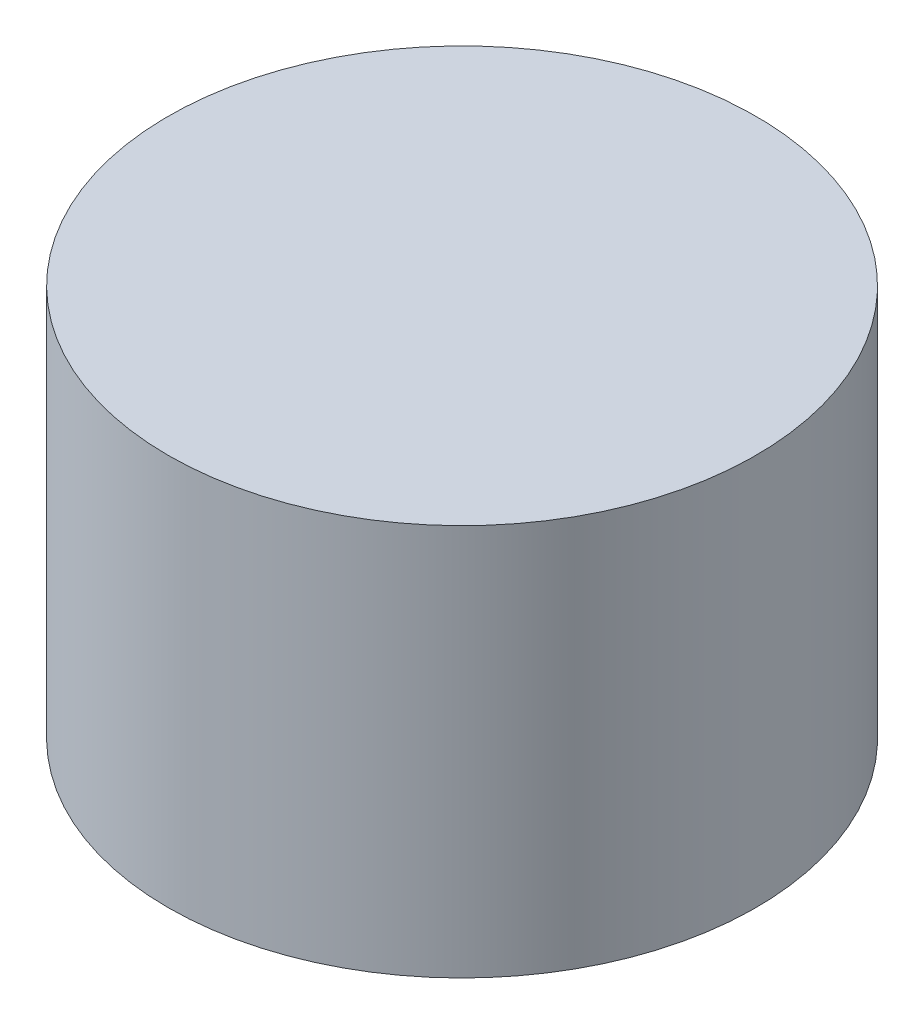
from build123d import *

# Parameters (mm, degrees)
SKETCH1_R           = 150
BOSS_EXTRUDE1_DEPTH = 200


with BuildPart() as part:
    # Sketch1 → Boss-Extrude1 (new body)
    with BuildSketch(Plane(origin=(0, 0, 0), x_dir=(1, 0, 0), z_dir=(0, 1, 0))):
        Circle(SKETCH1_R)
    extrude(amount=BOSS_EXTRUDE1_DEPTH)


solid = part.part
